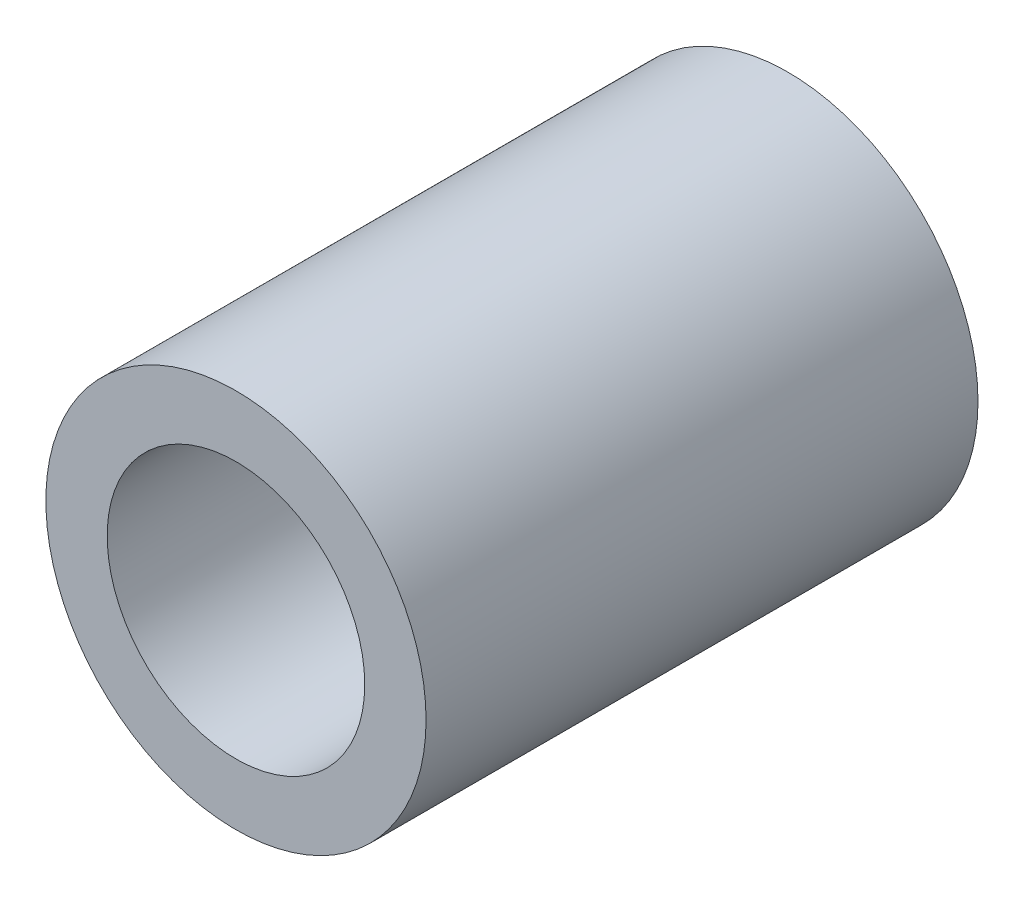
from build123d import *

# Parameters (mm, degrees)
SKETCH1_R           = 3.1
SKETCH1_R_2         = 2.1
BOSS_EXTRUDE1_DEPTH = 9


with BuildPart() as part:
    # Sketch1 → Boss-Extrude1 (new body)
    with BuildSketch(Plane.XY):
        Circle(SKETCH1_R)
        Circle(SKETCH1_R_2, mode=Mode.SUBTRACT)
    extrude(amount=BOSS_EXTRUDE1_DEPTH)


solid = part.part
